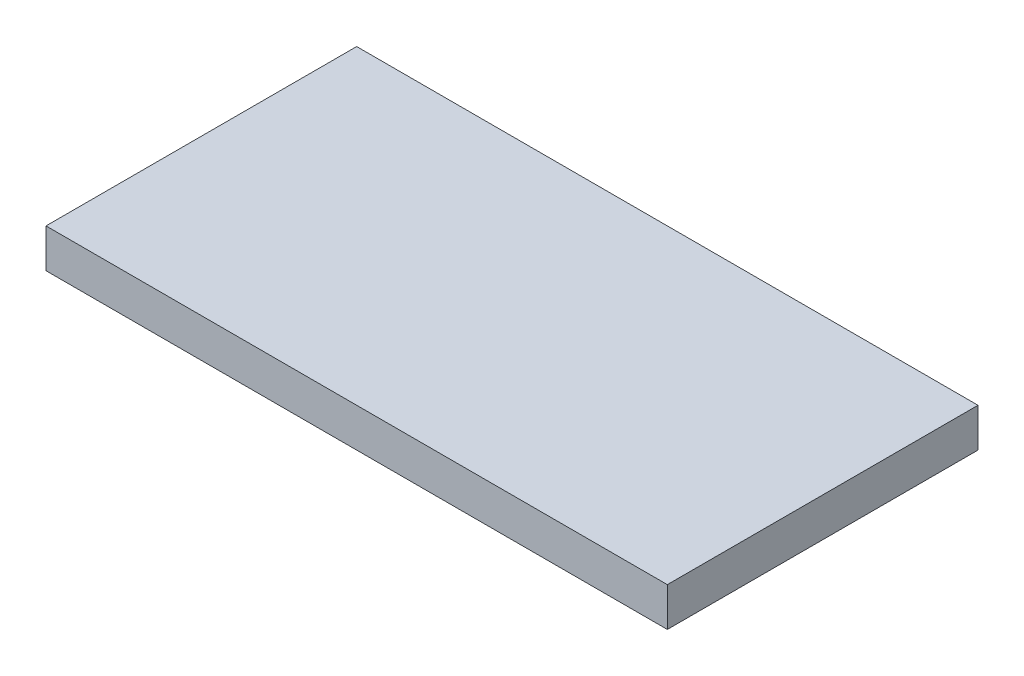
from build123d import *

# Parameters (mm, degrees)
SKETCH1_W           = 76.2
SKETCH1_H           = 38.1
BOSS_EXTRUDE1_DEPTH = 4.7625


with BuildPart() as part:
    # Sketch1 → Boss-Extrude1 (new body)
    with BuildSketch(Plane(origin=(0, 0, 0), x_dir=(1, 0, 0), z_dir=(0, 1, 0))):
        with Locations((38.1, -19.05)):
            Rectangle(SKETCH1_W, SKETCH1_H)
    extrude(amount=BOSS_EXTRUDE1_DEPTH)


solid = part.part
